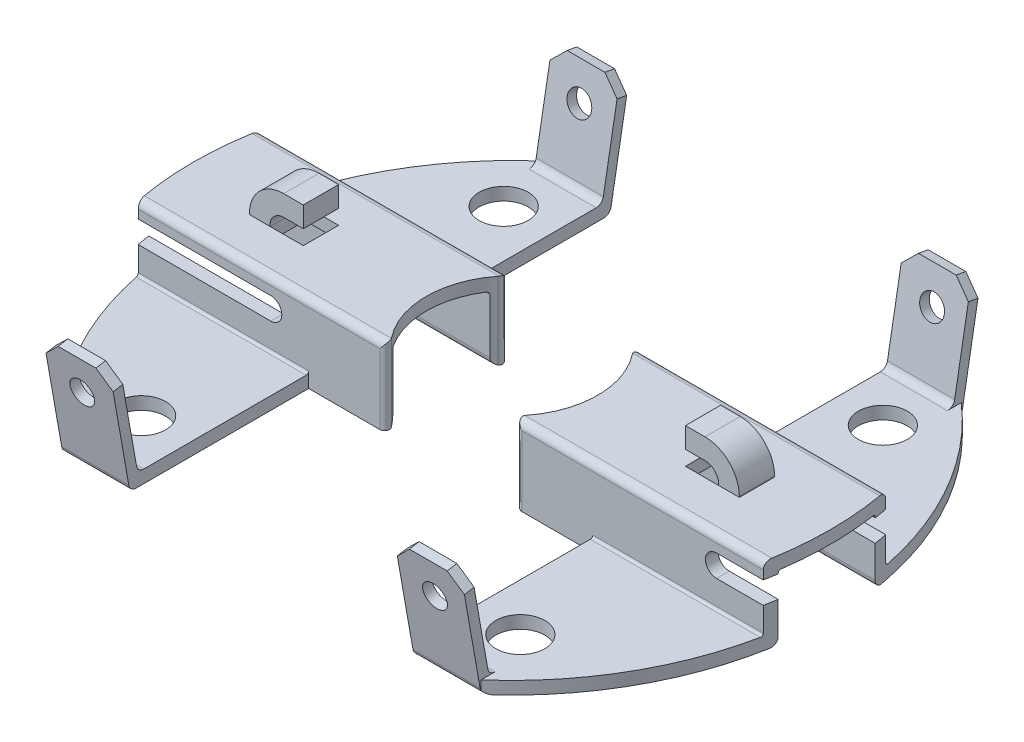
from build123d import *

# Parameters (mm, degrees)
SKETCH1_R               = 1.27
BOSS_EXTRUDE1_DEPTH     = 4.0132
BOSS_EXTRUDE1_2_DEPTH   = 4.0132
CUT_EXTRUDE1_DEPTH      = 17.51
CUT_EXTRUDE1_DEPTH_BACK = 17.51
CUT_EXTRUDE2_DEPTH      = 4.826
CUT_EXTRUDE3_DEPTH      = 4.826
SKETCH6_W               = 2.794
SKETCH6_H               = 1.8288
BOSS_EXTRUDE2_DEPTH     = 1.8288
CUT_EXTRUDE4_DEPTH      = 1.8288
CUT_EXTRUDE4_DEPTH_BACK = 1.8288
CUT_EXTRUDE7_DEPTH      = 5.0132001
BOSS_EXTRUDE3_START     = -0.254
BOSS_EXTRUDE3_DEPTH     = 3.481912
BOSS_EXTRUDE4_START     = -7.366
BOSS_EXTRUDE4_DEPTH     = 3.481912
CHAMFER1_SIZE           = 0.762
CHAMFER2_SIZE           = 0.762
FILLET1_R               = 0.381
FILLET2_R               = 0.381
SKETCH13_R              = 0.635
CUT_EXTRUDE8_DEPTH      = 3.175
SKETCH15_R              = 0.635
CUT_EXTRUDE9_DEPTH      = 3.175


with BuildPart() as part:
    # Sketch1 → Boss-Extrude1 (new body)
    with BuildSketch(Plane(origin=(0, 0, 0), x_dir=(1, 0, 0), z_dir=(0, 1, 0))):
        with BuildLine():
            Line((-7.366, 12.446), (-7.366, 3.175))
            Line((-7.366, 3.175), (-3.680809694, 3.175))
            ThreePointArc((-3.680809694, 3.175), (-3.452095308, 3.031479544), (-3.481847007, 2.763108108))
            ThreePointArc((-3.481847007, 2.763108108), (-4.445, 0), (-3.481847007, -2.763108108))
            ThreePointArc((-3.481847007, -2.763108108), (-3.452095308, -3.031479544), (-3.680809694, -3.175))
            Line((-3.680809694, -3.175), (-7.366, -3.175))
            Line((-7.366, -3.175), (-7.366, -12.446))
            Line((-7.366, -12.446), (-10.847911504, -12.446))
            ThreePointArc((-10.847911504, -12.446), (-16.51, 0), (-10.847911504, 12.446))
            Line((-10.847911504, 12.446), (-7.366, 12.446))
        make_face()
        with Locations((-9.8298, 9.398)):
            Circle(SKETCH1_R, mode=Mode.SUBTRACT)
        with Locations((-9.8298, -9.398)):
            Circle(SKETCH1_R, mode=Mode.SUBTRACT)
    extrude(amount=BOSS_EXTRUDE1_DEPTH)


with BuildPart() as body_2:
    # Sketch1 → Boss-Extrude1 2 (new body)
    with BuildSketch(Plane(origin=(0, 0, 0), x_dir=(1, 0, 0), z_dir=(0, 1, 0))):
        with BuildLine():
            Line((10.847911504, -12.446), (7.366, -12.446))
            Line((7.366, -12.446), (7.366, -3.175))
            Line((7.366, -3.175), (3.680809694, -3.175))
            ThreePointArc((3.680809694, -3.175), (3.452095308, -3.031479544), (3.481847007, -2.763108108))
            ThreePointArc((3.481847007, -2.763108108), (4.445, 0), (3.481847007, 2.763108108))
            ThreePointArc((3.481847007, 2.763108108), (3.452095308, 3.031479544), (3.680809694, 3.175))
            Line((3.680809694, 3.175), (7.366, 3.175))
            Line((7.366, 3.175), (7.366, 12.446))
            Line((7.366, 12.446), (10.847911504, 12.446))
            ThreePointArc((10.847911504, 12.446), (16.51, 0), (10.847911504, -12.446))
        make_face()
        with Locations((9.8298, -9.398)):
            Circle(SKETCH1_R, mode=Mode.SUBTRACT)
        with Locations((9.8298, 9.398)):
            Circle(SKETCH1_R, mode=Mode.SUBTRACT)
    extrude(amount=BOSS_EXTRUDE1_2_DEPTH)


with BuildPart() as cut_extrude1_tool:
    # Sketch2 → Cut-Extrude1 (new body, two sides)
    with BuildSketch(Plane(origin=(0, 0, 0), x_dir=(0, 0, -1), z_dir=(1, 0, 0))) as cut_extrude1_sk:
        with BuildLine():
            Line((12.446, 4.0132), (12.446, 0.6604))
            Line((12.446, 0.6604), (3.302, 0.6604))
            ThreePointArc((3.302, 0.6604), (3.212197439, 0.697597439), (3.175, 0.7874))
            Line((3.175, 0.7874), (3.175, 3.6322))
            ThreePointArc((3.175, 3.6322), (3.063407684, 3.901607684), (2.794, 4.0132))
            Line((2.794, 4.0132), (12.446, 4.0132))
        make_face()
        with BuildLine():
            Line((-3.175, 3.6322), (-3.175, 0.7874))
            ThreePointArc((-3.175, 0.7874), (-3.212197439, 0.697597439), (-3.302, 0.6604))
            Line((-3.302, 0.6604), (-12.446, 0.6604))
            Line((-12.446, 0.6604), (-12.446, 4.0132))
            Line((-12.446, 4.0132), (-2.794, 4.0132))
            ThreePointArc((-2.794, 4.0132), (-3.063407684, 3.901607684), (-3.175, 3.6322))
        make_face()
        with BuildLine():
            Line((-2.5146, 0.381), (-2.5146, 3.2258))
            ThreePointArc((-2.5146, 3.2258), (-2.477402561, 3.315602561), (-2.3876, 3.3528))
            Line((-2.3876, 3.3528), (2.3876, 3.3528))
            ThreePointArc((2.3876, 3.3528), (2.477402561, 3.315602561), (2.5146, 3.2258))
            Line((2.5146, 3.2258), (2.5146, 0.381))
            ThreePointArc((2.5146, 0.381), (2.626192316, 0.111592316), (2.8956, 0))
            Line((2.8956, 0), (-2.8956, 0))
            ThreePointArc((-2.8956, 0), (-2.626192316, 0.111592316), (-2.5146, 0.381))
        make_face()
    extrude(amount=CUT_EXTRUDE1_DEPTH)
    extrude(cut_extrude1_sk.sketch, amount=-CUT_EXTRUDE1_DEPTH_BACK)


with BuildPart() as part_1:
    add(part.part)

    # Cut-Extrude1: cut by cut_extrude1_tool
    add(cut_extrude1_tool.part, mode=Mode.SUBTRACT)


with BuildPart() as body_2_1:
    add(body_2.part)

    # Cut-Extrude1: cut by cut_extrude1_tool
    add(cut_extrude1_tool.part, mode=Mode.SUBTRACT)


with BuildPart() as cut_extrude2_tool:
    # Sketch4 → Cut-Extrude2 (new body)
    with BuildSketch(Plane(origin=(0, 0, -3.175), x_dir=(-1, 0, 0), z_dir=(0, 0, -1))):
        with BuildLine():
            Line((-16.760937072, 3.1877), (-9.332379901, 3.1877))
            ThreePointArc((-9.332379901, 3.1877), (-8.760879901, 2.6162), (-9.332379901, 2.0447))
            Line((-9.332379901, 2.0447), (-16.760937072, 2.0447))
            ThreePointArc((-16.760937072, 2.0447), (-17.332437072, 2.6162), (-16.760937072, 3.1877))
        make_face()
        with BuildLine():
            Line((17.976673039, 2.0447), (13.777379901, 2.0447))
            ThreePointArc((13.777379901, 2.0447), (13.205879901, 2.6162), (13.777379901, 3.1877))
            Line((13.777379901, 3.1877), (17.976673039, 3.1877))
            ThreePointArc((17.976673039, 3.1877), (18.548173039, 2.6162), (17.976673039, 2.0447))
        make_face()
    extrude(amount=-CUT_EXTRUDE2_DEPTH)


with BuildPart() as part_2:
    add(part_1.part)

    # Cut-Extrude2: cut by cut_extrude2_tool
    add(cut_extrude2_tool.part, mode=Mode.SUBTRACT)


with BuildPart() as body_2_2:
    add(body_2_1.part)

    # Cut-Extrude2: cut by cut_extrude2_tool
    add(cut_extrude2_tool.part, mode=Mode.SUBTRACT)


with BuildPart() as cut_extrude3_tool:
    # Sketch5 → Cut-Extrude3 (new body)
    with BuildSketch(Plane.XY.offset(3.175)):
        with BuildLine():
            Line((-16.760937072, 3.1877), (-9.332379901, 3.1877))
            ThreePointArc((-9.332379901, 3.1877), (-8.760879901, 2.6162), (-9.332379901, 2.0447))
            Line((-9.332379901, 2.0447), (-16.760937072, 2.0447))
            ThreePointArc((-16.760937072, 2.0447), (-17.332437072, 2.6162), (-16.760937072, 3.1877))
        make_face()
        with BuildLine():
            Line((17.976673039, 2.0447), (13.777379901, 2.0447))
            ThreePointArc((13.777379901, 2.0447), (13.205879901, 2.6162), (13.777379901, 3.1877))
            Line((13.777379901, 3.1877), (17.976673039, 3.1877))
            ThreePointArc((17.976673039, 3.1877), (18.548173039, 2.6162), (17.976673039, 2.0447))
        make_face()
    extrude(amount=-CUT_EXTRUDE3_DEPTH)


with BuildPart() as part_3:
    add(part_2.part)

    # Cut-Extrude3: cut by cut_extrude3_tool
    add(cut_extrude3_tool.part, mode=Mode.SUBTRACT)



with BuildPart() as body_2_3:
    add(body_2_2.part)

    # Cut-Extrude3: cut by cut_extrude3_tool
    add(cut_extrude3_tool.part, mode=Mode.SUBTRACT)


with BuildPart() as part_4:
    add(part_3.part)

    add(body_2_3.part)  # Boss-Extrude2 merges body 2
    # Sketch6 → Boss-Extrude2 (add)
    with BuildSketch(Plane(origin=(0, 4.0132, 0), x_dir=(1, 0, 0), z_dir=(0, 1, 0))):
        with Locations((-11.303, 0)):
            Rectangle(SKETCH6_W, SKETCH6_H)
        with Locations((11.303, 0)):
            Rectangle(SKETCH6_W, SKETCH6_H)
    extrude(amount=BOSS_EXTRUDE2_DEPTH)

    # Sketch7 → Cut-Extrude4 (cut, two sides)
    with BuildSketch(Plane.XY) as cut_extrude4_sk:
        with BuildLine():
            ThreePointArc((10.922, 4.7752), (11.442545099, 4.548601114), (11.631383394, 4.0132))
            Line((11.631383394, 4.0132), (9.906, 4.0132))
            Line((9.906, 4.0132), (9.906, 4.7752))
            Line((9.906, 4.7752), (10.922, 4.7752))
        make_face()
        with BuildLine():
            ThreePointArc((10.922, 5.842), (12.179235857, 5.321235857), (12.7, 4.064))
            Line((12.7, 4.064), (12.7, 5.842))
            Line((12.7, 5.842), (10.922, 5.842))
        make_face()
        with BuildLine():
            ThreePointArc((-10.922, 5.842), (-12.179235857, 5.321235857), (-12.7, 4.064))
            Line((-12.7, 4.064), (-12.7, 5.842))
            Line((-12.7, 5.842), (-10.922, 5.842))
        make_face()
        with BuildLine():
            Line((-9.906, 4.7752), (-10.922, 4.7752))
            ThreePointArc((-10.922, 4.7752), (-11.442545099, 4.548601114), (-11.631383394, 4.0132))
            Line((-11.631383394, 4.0132), (-9.906, 4.0132))
            Line((-9.906, 4.0132), (-9.906, 4.7752))
        make_face()
    extrude(amount=CUT_EXTRUDE4_DEPTH, mode=Mode.SUBTRACT)
    extrude(cut_extrude4_sk.sketch, amount=-CUT_EXTRUDE4_DEPTH_BACK, mode=Mode.SUBTRACT)

    # Sketch9 → Cut-Extrude7 (cut, through all)
    with BuildSketch(Plane(origin=(0, 4.0132, 0), x_dir=(1, 0, 0), z_dir=(0, 1, 0))):
        Polygon((-11.631383394, 0.9144), (-11.631383394, -0.9144), (-10.922, -0.9144), (-9.906, -0.9144), (-9.906, 0.9144), (-10.922, 0.9144), align=None)
        Polygon((10.922, -0.9144), (11.631383394, -0.9144), (11.631383394, 0.9144), (10.922, 0.9144), (9.906, 0.9144), (9.906, -0.9144), align=None)
    extrude(amount=-CUT_EXTRUDE7_DEPTH, mode=Mode.SUBTRACT)

    # Sketch10 → Boss-Extrude3 (add)
    with BuildSketch(Plane(origin=(7.62, 0, 0), x_dir=(0, 0, -1), z_dir=(1, 0, 0)).offset(BOSS_EXTRUDE3_START)):
        Polygon((-13.445606009, 5.669047385), (-12.446, 0), (-12.019737387, 0.508), (-12.94532367, 5.75726066), align=None)
        Polygon((12.94532367, 5.75726066), (12.019737387, 0.508), (12.446, 0), (13.445606009, 5.669047385), align=None)
    extrude(amount=BOSS_EXTRUDE3_DEPTH)

    # Sketch12 → Boss-Extrude4 (add)
    with BuildSketch(Plane(origin=(0, 0, 0), x_dir=(0, 0, -1), z_dir=(1, 0, 0)).offset(BOSS_EXTRUDE4_START)):
        Polygon((12.046609619, 0.6604), (12.94532367, 5.75726066), (13.445606009, 5.669047385), (12.446, 0), align=None)
        Polygon((-12.94532367, 5.75726066), (-12.046609619, 0.6604), (-12.446, 0), (-13.445606009, 5.669047385), align=None)
    extrude(amount=-BOSS_EXTRUDE4_DEPTH)

    # Chamfer1
    chamfer1_edges = [part_4.edges().sort_by_distance(p)[0] for p in [
        (10.847912, 5.713154022, 13.19546484),
        (7.366, 5.713154022, 13.19546484),
        (10.847912, 5.713154022, -13.19546484),
        (7.366, 5.713154022, -13.19546484),
    ]]
    chamfer(chamfer1_edges, length=CHAMFER1_SIZE)

    # Chamfer2
    chamfer2_edges = [part_4.edges().sort_by_distance(p)[0] for p in [
        (-7.366, 5.713154022, -13.19546484),
        (-10.847912, 5.713154022, -13.19546484),
        (-7.366, 5.713154022, 13.19546484),
        (-10.847912, 5.713154022, 13.19546484),
    ]]
    chamfer(chamfer2_edges, length=CHAMFER2_SIZE)

    # Fillet1
    fillet1_edges = [part_4.edges().sort_by_distance(p)[0] for p in [
        (-9.106955752, 0, -12.446),
        (-9.106956, 0.6604, -12.046609619),
        (-9.106956, 0.6604, 12.046609619),
        (-9.106955752, 0, 12.446),
    ]]
    fillet(fillet1_edges, radius=FILLET1_R)

    # Fillet2
    fillet2_edges = [part_4.edges().sort_by_distance(p)[0] for p in [
        (9.106955752, 0, -12.446),
        (9.106956, 0.6604, 12.046609619),
        (9.106956, 0.6604, -12.046609619),
        (9.106955752, 0, 12.446),
    ]]
    fillet(fillet2_edges, radius=FILLET2_R)

    # Sketch13 → Cut-Extrude8 (cut)
    with BuildSketch(Plane(origin=(0, -2.128391352, -12.070707179), x_dir=(-1, 0, 0), z_dir=(0, -0.173648178, -0.984807753))):
        with Locations((-9.144, 6.139726798)):
            Circle(SKETCH13_R)
        with Locations((9.144, 6.139726798)):
            Circle(SKETCH13_R)
    extrude(amount=-CUT_EXTRUDE8_DEPTH, mode=Mode.SUBTRACT)

    # Sketch15 → Cut-Extrude9 (cut)
    with BuildSketch(Plane(origin=(0, -2.128391352, 12.070707179), x_dir=(1, 0, 0), z_dir=(0, -0.173648178, 0.984807753))):
        with Locations((-9.144, 6.139726798)):
            Circle(SKETCH15_R)
        with Locations((9.144, 6.139726798)):
            Circle(SKETCH15_R)
    extrude(amount=-CUT_EXTRUDE9_DEPTH, mode=Mode.SUBTRACT)


solid = part_4.part
